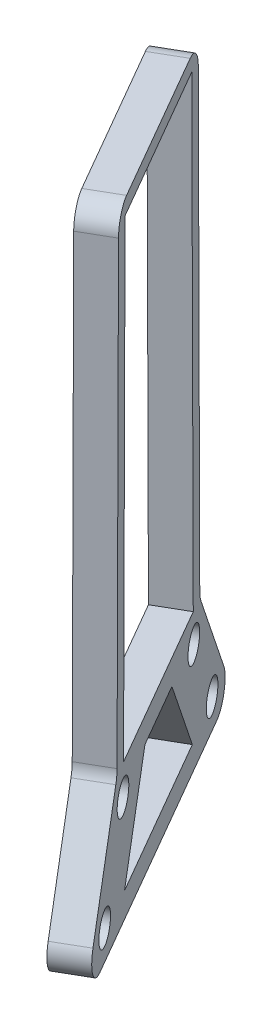
from build123d import *

# Parameters (mm, degrees)
SKETCH1_R           = 2.15
BOSS_EXTRUDE1_DEPTH = 4.45
FILLET1_R           = 3


with BuildPart() as part:
    # Sketch1 → Boss-Extrude1 (new body)
    with BuildSketch(Plane(origin=(7.87040158, 0, -4.543978471), x_dir=(0.5, 0, 0.866025404), z_dir=(-0.866025404, 0, 0.5))):
        Polygon((53.851280609, 136.798849573), (28.020561976, 136.798849573), (25.605878822, 136.798849573), (13.788638888, 118.055853922), (68.083203696, 118.055853922), (56.265963763, 136.798849573), align=None)
        with Locations((21.039254626, 122.055853922)):
            Circle(SKETCH1_R, mode=Mode.SUBTRACT)
        Polygon((53.501781192, 121.427351747), (28.370061392, 121.427351747), (35.935921292, 133.427351747), (45.935921292, 133.427351747), align=None, mode=Mode.SUBTRACT)
        with BuildLine():
            ThreePointArc((28.307564738, 134.891096687), (29.498811561, 134.132697376), (29.962587959, 132.798849573))
            ThreePointArc((29.962587959, 132.798849573), (28.449874626, 130.745470479), (26.040387304, 131.581555509))
            Line((26.040387304, 131.581555509), (25.535036631, 130.843863418))
            Line((25.535036631, 130.843863418), (25.213105243, 131.064400205))
            ThreePointArc((25.213105243, 131.064400205), (24.994059417, 131.449211896), (24.831600224, 131.861119802))
            Line((24.831600224, 131.861119802), (25.010769387, 134.182842957))
            ThreePointArc((25.010769387, 134.182842957), (25.234503174, 134.564948053), (25.509996288, 134.911595794))
            Line((25.509996288, 134.911595794), (27.610252102, 135.917292326))
            ThreePointArc((27.610252102, 135.917292326), (28.053031716, 135.91458573), (28.490984023, 135.849325565))
            Line((28.490984023, 135.849325565), (28.812915411, 135.628788778))
            Line((28.812915411, 135.628788778), (28.307564738, 134.891096687))
        make_face(mode=Mode.SUBTRACT)
        with Locations((54.059254626, 132.798849573)):
            Circle(SKETCH1_R, mode=Mode.SUBTRACT)
        with Locations((60.832587959, 122.055853922)):
            Circle(SKETCH1_R, mode=Mode.SUBTRACT)
        Polygon((28.020561976, 136.798849573), (28.577056843, 200.566845224), (53.294785741, 200.566845224), (53.851280609, 136.798849573), (56.265963763, 136.798849573), (55.69201516, 202.566845224), (26.179827424, 202.566845224), (25.605878822, 136.798849573), align=None)
        with BuildLine():
            ThreePointArc((26.040387304, 131.581555509), (26.038865627, 134.013925327), (28.307564738, 134.891096687))
            Line((28.307564738, 134.891096687), (28.812915411, 135.628788778))
            Line((28.812915411, 135.628788778), (28.490984023, 135.849325565))
            ThreePointArc((28.490984023, 135.849325565), (28.053031716, 135.91458573), (27.610252102, 135.917292326))
            Line((27.610252102, 135.917292326), (25.509996288, 134.911595794))
            ThreePointArc((25.509996288, 134.911595794), (25.234503174, 134.564948053), (25.010769387, 134.182842957))
            Line((25.010769387, 134.182842957), (24.831600224, 131.861119802))
            ThreePointArc((24.831600224, 131.861119802), (24.994059417, 131.449211896), (25.213105243, 131.064400205))
            Line((25.213105243, 131.064400205), (25.535036631, 130.843863418))
            Line((25.535036631, 130.843863418), (26.040387304, 131.581555509))
        make_face()
    extrude(amount=BOSS_EXTRUDE1_DEPTH)

    # Fillet1
    fillet1_edges = [part.edges().sort_by_distance(p)[0] for p in [
        (12.8378145, 118.055853922, 8.50983309),
        (18.746434467, 136.798849573, 18.743863075),
        (19.033408769, 202.566845224, 19.240917146),
        (33.789502636, 202.566845224, 44.799221446),
        (34.076476938, 136.798849573, 45.296275517),
        (39.985096905, 118.055853922, 55.530305501),
    ]]
    fillet(fillet1_edges, radius=FILLET1_R)


solid = part.part
